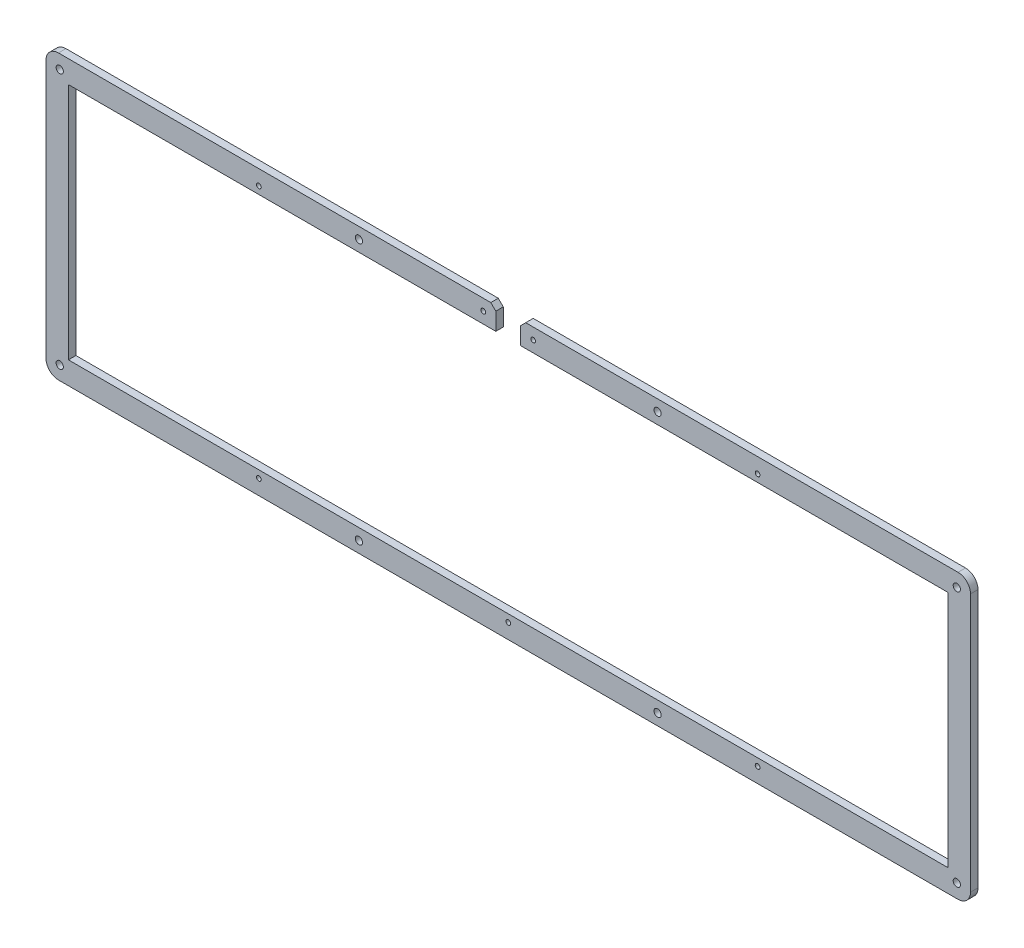
from build123d import *

# Parameters (mm, degrees)
MODEL_R             = 1.45
MODEL_R_2           = 0.95
BOSS_EXTRUDE1_DEPTH = 3


with BuildPart() as part:
    # Model → Boss-Extrude1 (new body)
    with BuildSketch(Plane.XY):
        with BuildLine():
            Line((5, 113.6), (178.3875, 113.6))
            Line((178.3875, 113.6), (180.3875, 111.6))
            Line((180.3875, 111.6), (180.3875, 104.6))
            Line((180.3875, 104.6), (9, 104.6))
            Line((9, 104.6), (9, 9))
            Line((9, 9), (361.775, 9))
            Line((361.775, 9), (361.775, 104.6))
            Line((361.775, 104.6), (190.3875, 104.6))
            Line((190.3875, 104.6), (190.3875, 111.6))
            Line((190.3875, 111.6), (192.3875, 113.6))
            Line((192.3875, 113.6), (365.775, 113.6))
            ThreePointArc((365.775, 113.6), (369.310533906, 112.135533906), (370.775, 108.6))
            Line((370.775, 108.6), (370.775, 5))
            ThreePointArc((370.775, 5), (369.310533906, 1.464466094), (365.775, 0))
            Line((365.775, 0), (5, 0))
            ThreePointArc((5, 0), (1.464466094, 1.464466094), (0, 5))
            Line((0, 5), (0, 108.6))
            ThreePointArc((0, 108.6), (1.464466094, 112.135533906), (5, 113.6))
        make_face()
        with Locations((245.275, 109.1)):
            Circle(MODEL_R, mode=Mode.SUBTRACT)
        with Locations((125.5, 109.1)):
            Circle(MODEL_R, mode=Mode.SUBTRACT)
        with Locations((245.275, 4.5)):
            Circle(MODEL_R, mode=Mode.SUBTRACT)
        with Locations((285.3875, 6)):
            Circle(MODEL_R_2, mode=Mode.SUBTRACT)
        with Locations((185.3875, 6)):
            Circle(MODEL_R_2, mode=Mode.SUBTRACT)
        with Locations((85.3875, 6)):
            Circle(MODEL_R_2, mode=Mode.SUBTRACT)
        with Locations((285.3875, 107.6)):
            Circle(MODEL_R_2, mode=Mode.SUBTRACT)
        with Locations((85.3875, 107.6)):
            Circle(MODEL_R_2, mode=Mode.SUBTRACT)
        with Locations((365.275, 108.1)):
            Circle(MODEL_R, mode=Mode.SUBTRACT)
        with Locations((365.275, 5.5)):
            Circle(MODEL_R, mode=Mode.SUBTRACT)
        with Locations((5.5, 5.5)):
            Circle(MODEL_R, mode=Mode.SUBTRACT)
        with Locations((5.5, 108.1)):
            Circle(MODEL_R, mode=Mode.SUBTRACT)
        with Locations((175.3875, 109.1)):
            Circle(MODEL_R_2, mode=Mode.SUBTRACT)
        with Locations((195.3875, 109.1)):
            Circle(MODEL_R_2, mode=Mode.SUBTRACT)
        with Locations((125.5, 4.5)):
            Circle(MODEL_R, mode=Mode.SUBTRACT)
    extrude(amount=BOSS_EXTRUDE1_DEPTH)


solid = part.part
